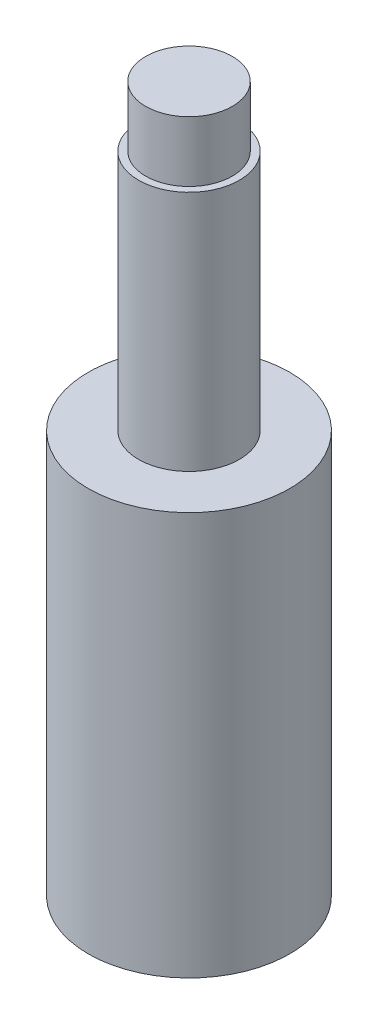
from build123d import *

# Parameters (mm, degrees)
SKETCH1_R           = 5
BOSS_EXTRUDE1_DEPTH = 20
SKETCH2_R           = 2.5
BOSS_EXTRUDE2_DEPTH = 12
SKETCH3_R           = 2.15
BOSS_EXTRUDE3_DEPTH = 3


with BuildPart() as part:
    # Sketch1 → Boss-Extrude1 (new body)
    with BuildSketch(Plane(origin=(0, 0, 0), x_dir=(1, 0, 0), z_dir=(0, 1, 0))):
        Circle(SKETCH1_R)
    extrude(amount=BOSS_EXTRUDE1_DEPTH)

    # Sketch2 → Boss-Extrude2 (add)
    with BuildSketch(Plane(origin=(0, 20, 0), x_dir=(1, 0, 0), z_dir=(0, 1, 0))):
        Circle(SKETCH2_R)
    extrude(amount=BOSS_EXTRUDE2_DEPTH)

    # Sketch3 → Boss-Extrude3 (add)
    with BuildSketch(Plane(origin=(0, 32, 0), x_dir=(1, 0, 0), z_dir=(0, 1, 0))):
        Circle(SKETCH3_R)
    extrude(amount=BOSS_EXTRUDE3_DEPTH)


solid = part.part
